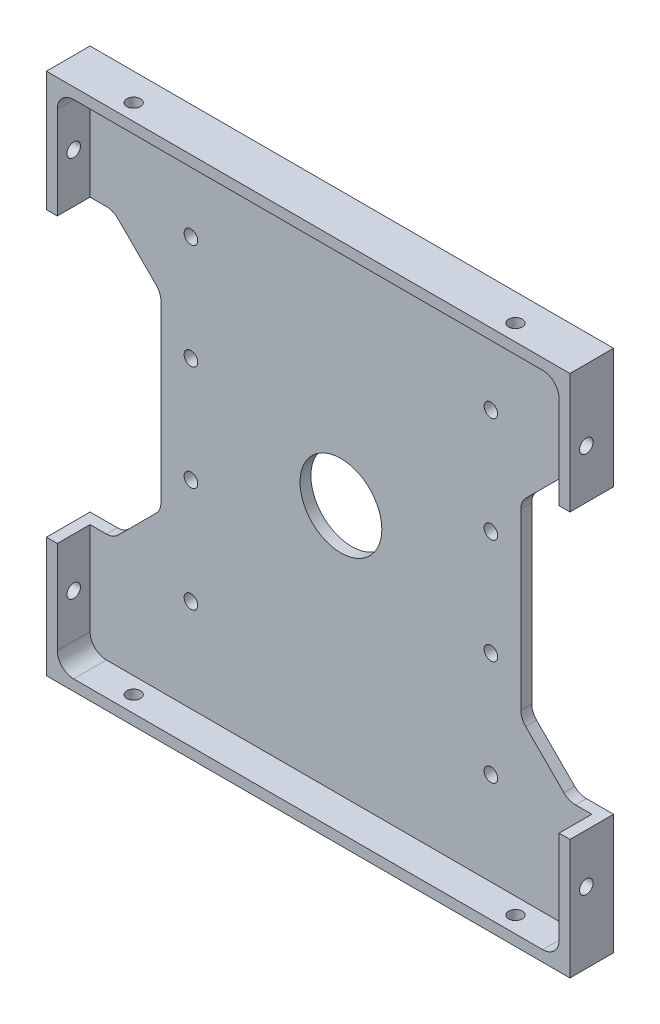
from build123d import *

# Parameters (mm, degrees)
SKETCH1_W                      = 96
SKETCH1_H                      = 96
BOSS_EXTRUDE1_DEPTH            = 8
SKETCH2_W                      = 92
SKETCH2_H                      = 92
COMPONENT_PLATFORM_DEPTH       = 6
CABLE_SLOTS_DEPTH              = 6
SKETCH4_R                      = 7.5
CENTER_MASS_CUT_DEPTH          = 6
INNER_CORNER_FILLETS_R         = 3
M3X0_5_TAPPED_HOLE1_AT_2_COUNT = 2
M3X0_5_TAPPED_HOLE1_AT_2_PITCH = 70
M3X0_5_TAPPED_HOLE2_AT_2_COUNT = 2
M3X0_5_TAPPED_HOLE2_AT_2_PITCH = 70
M3X0_5_TAPPED_HOLE3_D          = 2.5


with BuildPart() as part:
    # Sketch1 → Boss-Extrude1 (new body)
    with BuildSketch(Plane.XY):
        Rectangle(SKETCH1_W, SKETCH1_H)
    extrude(amount=BOSS_EXTRUDE1_DEPTH)

    # Sketch2 → Component Platform (cut)
    with BuildSketch(Plane.XY.offset(8)):
        Rectangle(SKETCH2_W, SKETCH2_H)
    extrude(amount=-COMPONENT_PLATFORM_DEPTH, mode=Mode.SUBTRACT)

    # Sketch3 → Cable Slots (cut, symmetric)
    with BuildSketch(Plane.XY.offset(2)):
        with BuildLine():
            Line((-40.878679656, -25.121320344), (-33.878679656, -18.121320344))
            ThreePointArc((-33.878679656, -18.121320344), (-33.228361402, -17.148050297), (-33, -16))
            Line((-33, -16), (-33, 16))
            ThreePointArc((-33, 16), (-33.228361402, 17.148050297), (-33.878679656, 18.121320344))
            Line((-33.878679656, 18.121320344), (-40.878679656, 25.121320344))
            ThreePointArc((-40.878679656, 25.121320344), (-41.851949703, 25.771638598), (-43, 26))
            Line((-43, 26), (-48, 26))
            Line((-48, 26), (-48, -26))
            Line((-48, -26), (-43, -26))
            ThreePointArc((-43, -26), (-41.851949703, -25.771638598), (-40.878679656, -25.121320344))
        make_face()
        with BuildLine():
            Line((48, -26), (48, 26))
            Line((48, 26), (43, 26))
            ThreePointArc((43, 26), (41.851949703, 25.771638598), (40.878679656, 25.121320344))
            Line((40.878679656, 25.121320344), (33.878679656, 18.121320344))
            ThreePointArc((33.878679656, 18.121320344), (33.228361402, 17.148050297), (33, 16))
            Line((33, 16), (33, -16))
            ThreePointArc((33, -16), (33.228361402, -17.148050297), (33.878679656, -18.121320344))
            Line((33.878679656, -18.121320344), (40.878679656, -25.121320344))
            ThreePointArc((40.878679656, -25.121320344), (41.851949703, -25.771638598), (43, -26))
            Line((43, -26), (48, -26))
        make_face()
    extrude(amount=CABLE_SLOTS_DEPTH, both=True, mode=Mode.SUBTRACT)

    # Sketch4 → Center Mass Cut (cut)
    with BuildSketch(Plane.XY.offset(2)):
        Circle(SKETCH4_R)
    extrude(amount=-CENTER_MASS_CUT_DEPTH, mode=Mode.SUBTRACT)

    # Inner Corner Fillets
    inner_corner_fillets_edges = [part.edges().sort_by_distance(p)[0] for p in [
        (-46, -46, 5),
        (-46, 46, 5),
        (46, 46, 5),
        (46, -46, 5),
    ]]
    fillet(inner_corner_fillets_edges, radius=INNER_CORNER_FILLETS_R)

    # Sketch10 → M3x0.5 Tapped Hole1 (revolve, cut)
    with BuildSketch(Plane(origin=(48, -35, 5), x_dir=(0, 0, -1), z_dir=(0, 1, 0))):
        Polygon((0, 0), (0, 10.751075774), (1.25, 10), (1.25, 0), align=None)
    m3x0_5_tapped_hole1 = revolve(axis=Axis((54.35, -35, 5), (-1, 0, 0)), mode=Mode.SUBTRACT)

    # M3x0.5 Tapped Hole1 at 2: M3x0.5 Tapped Hole1 ×2
    with Locations(*[(0, i * M3X0_5_TAPPED_HOLE1_AT_2_PITCH, 0) for i in range(1, M3X0_5_TAPPED_HOLE1_AT_2_COUNT)]):
        add(m3x0_5_tapped_hole1, mode=Mode.SUBTRACT)

    # Sketch13 → M3x0.5 Tapped Hole2 (revolve, cut)
    with BuildSketch(Plane(origin=(-35, -48, 5), x_dir=(0, 0, -1), z_dir=(1, 0, 0))):
        Polygon((0, 0), (0, 10.751075774), (1.25, 10), (1.25, 0), align=None)
    m3x0_5_tapped_hole2 = revolve(axis=Axis((-35, -54.35, 5), (0, 1, 0)), mode=Mode.SUBTRACT)

    # M3x0.5 Tapped Hole2 at 2: M3x0.5 Tapped Hole2 ×2
    with Locations(*[(i * M3X0_5_TAPPED_HOLE2_AT_2_PITCH, 0, 0) for i in range(1, M3X0_5_TAPPED_HOLE2_AT_2_COUNT)]):
        add(m3x0_5_tapped_hole2, mode=Mode.SUBTRACT)

    # Mirror1: M3x0.5 Tapped Hole1 across plane
    add(m3x0_5_tapped_hole1.mirror(Plane(origin=(0, 0, 0), x_dir=(0, 0, 1), z_dir=(1, 0, 0))), mode=Mode.SUBTRACT)

    # Mirror1 copy 1 sketch → Mirror1 copy 1 (revolve, cut)
    with BuildSketch(Plane(origin=(-48, 35, 5), x_dir=(0, 0, -1), z_dir=(0, 1, 0))):
        Polygon((0, 0), (0, -10.751075774), (1.25, -10), (1.25, 0), align=None)
    revolve(axis=Axis((-54.35, 35, 5), (-1, 0, 0)), mode=Mode.SUBTRACT)

    # Mirror2: M3x0.5 Tapped Hole2 across plane
    add(m3x0_5_tapped_hole2.mirror(Plane(origin=(0, 0, 0), x_dir=(0, 0, 1), z_dir=(0, -1, 0))), mode=Mode.SUBTRACT)

    # Mirror2 copy 1 sketch → Mirror2 copy 1 (revolve, cut)
    with BuildSketch(Plane(origin=(35, 48, 5), x_dir=(0, 0, -1), z_dir=(1, 0, 0))):
        Polygon((0, 0), (0, -10.751075774), (1.25, -10), (1.25, 0), align=None)
    revolve(axis=Axis((35, 54.35, 5), (0, 1, 0)), mode=Mode.SUBTRACT)

    # M3x0.5 Tapped Hole3 (through all)
    with Locations(Plane.XY.offset(2)):
        with Locations((-27.5, 28.95), (-27.5, 9.65), (-27.5, -9.65), (-27.5, -28.95), (27.5, -28.95), (27.5, -9.65), (27.5, 9.65), (27.5, 28.95)):
            Hole(M3X0_5_TAPPED_HOLE3_D / 2)


solid = part.part
